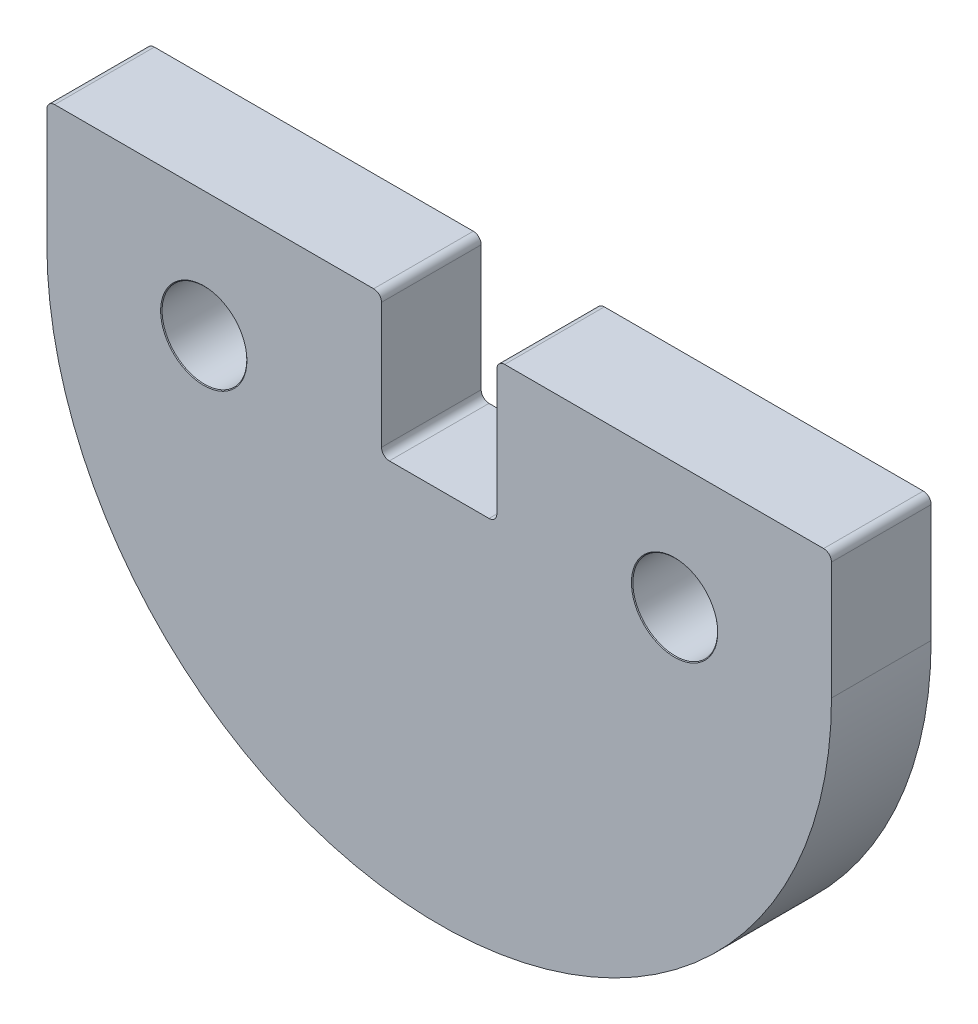
from build123d import *

# Parameters (mm, degrees)
BOSS_EXTRUDE1_DEPTH              = 3.175
M2_5_CLEARANCE_HOLE1_D           = 2.7
M2_5_CLEARANCE_HOLE1_CSINK_D     = 2.75
M2_5_CLEARANCE_HOLE1_CSINK_ANGLE = 100
FILLET1_R                        = 0.25


with BuildPart() as part:
    # Sketch1 → Boss-Extrude1 (new body)
    with BuildSketch(Plane.XY):
        with BuildLine():
            Line((-12.5, 4), (-12.5, 0))
            ThreePointArc((-12.5, 0), (0, -12.5), (12.5, 0))
            Line((12.5, 0), (12.5, 4))
            Line((12.5, 4), (1.8375, 4))
            Line((1.8375, 4), (1.8375, -0.5))
            Line((1.8375, -0.5), (-1.8375, -0.5))
            Line((-1.8375, -0.5), (-1.8375, 4))
            Line((-1.8375, 4), (-12.5, 4))
        make_face()
    extrude(amount=BOSS_EXTRUDE1_DEPTH)

    # M2.5 Clearance Hole1 (through all)
    with Locations(Plane.XY.offset(3.175)):
        with Locations((-7.5, 0), (7.5, 0)):
            CounterSinkHole(M2_5_CLEARANCE_HOLE1_D / 2, M2_5_CLEARANCE_HOLE1_CSINK_D / 2, counter_sink_angle=M2_5_CLEARANCE_HOLE1_CSINK_ANGLE)

    # Fillet1
    fillet1_edges = [part.edges().sort_by_distance(p)[0] for p in [
        (-12.5, 4, 1.5875),
        (-1.8375, 4, 1.5875),
        (-1.8375, -0.5, 1.5875),
        (1.8375, -0.5, 1.5875),
        (1.8375, 4, 1.5875),
        (12.5, 4, 1.5875),
    ]]
    fillet(fillet1_edges, radius=FILLET1_R)


solid = part.part
